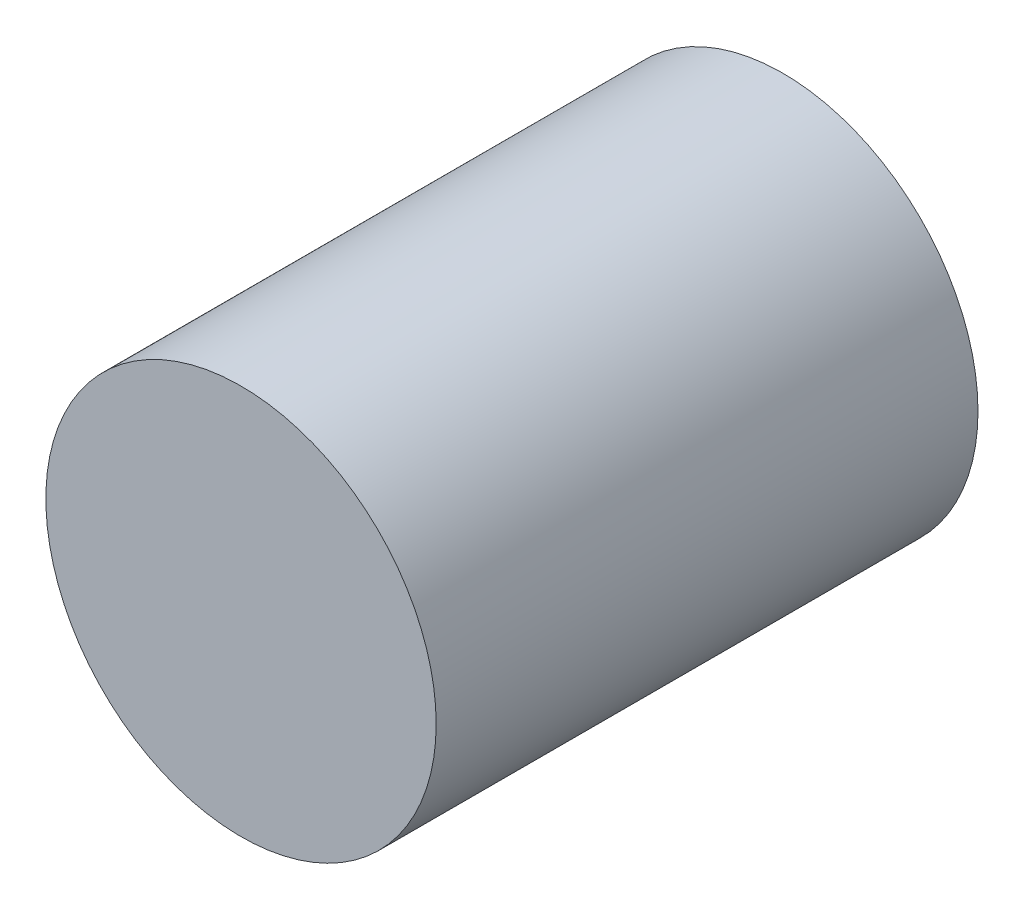
from build123d import *

# Parameters (mm, degrees)
SKETCH_1_R      = 19
EXTRUDE_1_DEPTH = 52.75


with BuildPart() as part:
    # 草图1 → 凸台-拉伸1 (new body)
    with BuildSketch(Plane.XY):
        Circle(SKETCH_1_R)
    extrude(amount=EXTRUDE_1_DEPTH)


solid = part.part
